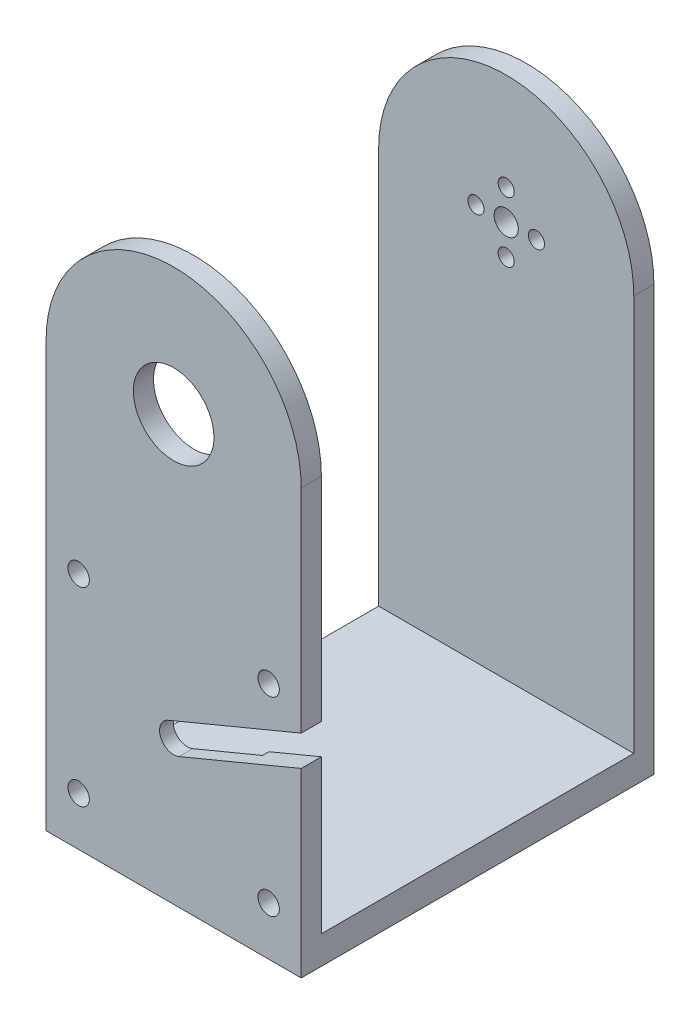
from build123d import *

# Parameters (mm, degrees)
BOSS_EXTRUDE1_DEPTH  = 7
BOSS_EXTRUDE2_DEPTH  = 60.3
SKETCH1_5_W          = 63.3
SKETCH1_5_H          = 5
BOSS_EXTRUDE3_DEPTH  = 60.3
SKETCH2_R            = 2.65
SKETCH2_R_2          = 3.5
CUT_EXTRUDE1_DEPTH   = 5
SKETCH2_3_R          = 19.05
CUT_EXTRUDE2_DEPTH   = 1.6
CUT_EXTRUDE3_DEPTH   = 5
BOSS_EXTRUDE6_DEPTH  = 5
BOSS_EXTRUDE10_DEPTH = 5
SKETCH15_R           = 3
SKETCH15_R_2         = 2
CUT_EXTRUDE7_DEPTH   = 5
SKETCH16_R           = 10
CUT_EXTRUDE8_DEPTH   = 5
SKETCH27_W           = 25
SKETCH27_H           = 87.5
CUT_EXTRUDE10_DEPTH  = 7
SKETCH33_R           = 3.5
BOSS_EXTRUDE18_DEPTH = 20


with BuildPart() as part:
    # Sketch1 → Boss-Extrude1 (new body)
    with BuildSketch(Plane(origin=(0, 0, 0), x_dir=(1, 0, 0), z_dir=(0, 1, 0))):
        Polygon((-1.592164976, 82.5), (61.707835024, 82.5), (86.707835024, 82.5), (86.707835024, -5), (61.707835024, -5), (-1.592164976, -5), (-26.592164976, -5), (-26.592164976, 82.5), align=None)
    extrude(amount=-BOSS_EXTRUDE1_DEPTH)

    # Sketch1_3 → Boss-Extrude2 (add)
    with BuildSketch(Plane(origin=(0, 0, 0), x_dir=(1, 0, 0), z_dir=(0, 1, 0))):
        Polygon((1.407835024, 0), (58.707835024, 0), (61.707835024, 0), (61.707835024, -5), (-1.592164976, -5), (-1.592164976, 0), align=None)
    extrude(amount=BOSS_EXTRUDE2_DEPTH)

    # Sketch1_5 → Boss-Extrude3 (add)
    with BuildSketch(Plane(origin=(0, 0, 0), x_dir=(1, 0, 0), z_dir=(0, 1, 0))):
        with Locations((30.057835024, 80)):
            Rectangle(SKETCH1_5_W, SKETCH1_5_H)
    extrude(amount=BOSS_EXTRUDE3_DEPTH)

    # Sketch2 → Cut-Extrude1 (cut)
    with BuildSketch(Plane(origin=(0, 0, 0), x_dir=(-1, 0, 0), z_dir=(0, 0, -1))):
        with Locations((-6.487835024, 52.22)):
            Circle(SKETCH2_R)
        with Locations((-53.627835024, 52.22)):
            Circle(SKETCH2_R)
        with Locations((-53.627835024, 5.08)):
            Circle(SKETCH2_R)
        with Locations((-6.487835024, 5.08)):
            Circle(SKETCH2_R)
        with Locations((-30.057835024, 28.65)):
            Circle(SKETCH2_R_2)
    extrude(amount=-CUT_EXTRUDE1_DEPTH, mode=Mode.SUBTRACT)

    # Sketch2_3 → Cut-Extrude2 (cut)
    with BuildSketch(Plane(origin=(0, 0, 0), x_dir=(-1, 0, 0), z_dir=(0, 0, -1))):
        with Locations((-30.057835024, 28.65)):
            Circle(SKETCH2_3_R)
    extrude(amount=-CUT_EXTRUDE2_DEPTH, mode=Mode.SUBTRACT)

    # Sketch4 → Cut-Extrude3 (cut)
    with BuildSketch(Plane.XY.offset(5)):
        Polygon((28.713159107, 31.881384638), (61.707835024, 45.611457374), (61.707835024, 38.029568262), (31.402510942, 25.418615362), align=None)
    extrude(amount=-CUT_EXTRUDE3_DEPTH, mode=Mode.SUBTRACT)

    # Sketch7 → Boss-Extrude6 (add)
    with BuildSketch(Plane(origin=(0, 0, -82.5), x_dir=(-1, 0, 0), z_dir=(0, 0, -1))):
        with BuildLine():
            Line((-61.707835024, 60.3), (-61.707835024, 98.3))
            ThreePointArc((-61.707835024, 98.3), (-30.057835024, 129.95), (1.592164976, 98.3))
            Line((1.592164976, 98.3), (1.592164976, 60.3))
            Line((1.592164976, 60.3), (-61.707835024, 60.3))
        make_face()
    extrude(amount=-BOSS_EXTRUDE6_DEPTH)

    # Sketch8 → Boss-Extrude10 (add)
    with BuildSketch(Plane.XY.offset(5)):
        with BuildLine():
            Line((-1.592164976, 60.3), (-1.592164976, 98.3))
            ThreePointArc((-1.592164976, 98.3), (30.057835024, 129.95), (61.707835024, 98.3))
            Line((61.707835024, 98.3), (61.707835024, 60.3))
            Line((61.707835024, 60.3), (-1.592164976, 60.3))
        make_face()
    extrude(amount=-BOSS_EXTRUDE10_DEPTH)

    # Sketch15 → Cut-Extrude7 (cut)
    with BuildSketch(Plane(origin=(0, 0, -82.5), x_dir=(-1, 0, 0), z_dir=(0, 0, -1))):
        with Locations((-30.057835024, 98.3)):
            Circle(SKETCH15_R)
        with Locations((-30.057835024, 105.8)):
            Circle(SKETCH15_R_2)
        with Locations((-22.557835024, 98.3)):
            Circle(SKETCH15_R_2)
        with Locations((-30.057835024, 90.8)):
            Circle(SKETCH15_R_2)
        with Locations((-37.557835024, 98.3)):
            Circle(SKETCH15_R_2)
    extrude(amount=-CUT_EXTRUDE7_DEPTH, mode=Mode.SUBTRACT)

    # Sketch16 → Cut-Extrude8 (cut)
    with BuildSketch(Plane.XY.offset(5)):
        with Locations((30.057835024, 98.3)):
            Circle(SKETCH16_R)
    extrude(amount=-CUT_EXTRUDE8_DEPTH, mode=Mode.SUBTRACT)

    # Sketch27 → Cut-Extrude10 (cut)
    with BuildSketch(Plane(origin=(0, 0, 0), x_dir=(1, 0, 0), z_dir=(0, 1, 0))):
        with Locations((74.207835024, 38.75)):
            Rectangle(SKETCH27_W, SKETCH27_H)
        with Locations((-14.092164976, 38.75)):
            Rectangle(SKETCH27_W, SKETCH27_H)
    extrude(amount=-CUT_EXTRUDE10_DEPTH, mode=Mode.SUBTRACT)

    # Sketch33 → Boss-Extrude18 (add)
    with BuildSketch(Plane.XY.offset(-77.5)):
        with Locations((30.057835024, 30.15)):
            Circle(SKETCH33_R)
    extrude(amount=-BOSS_EXTRUDE18_DEPTH)


solid = part.part
